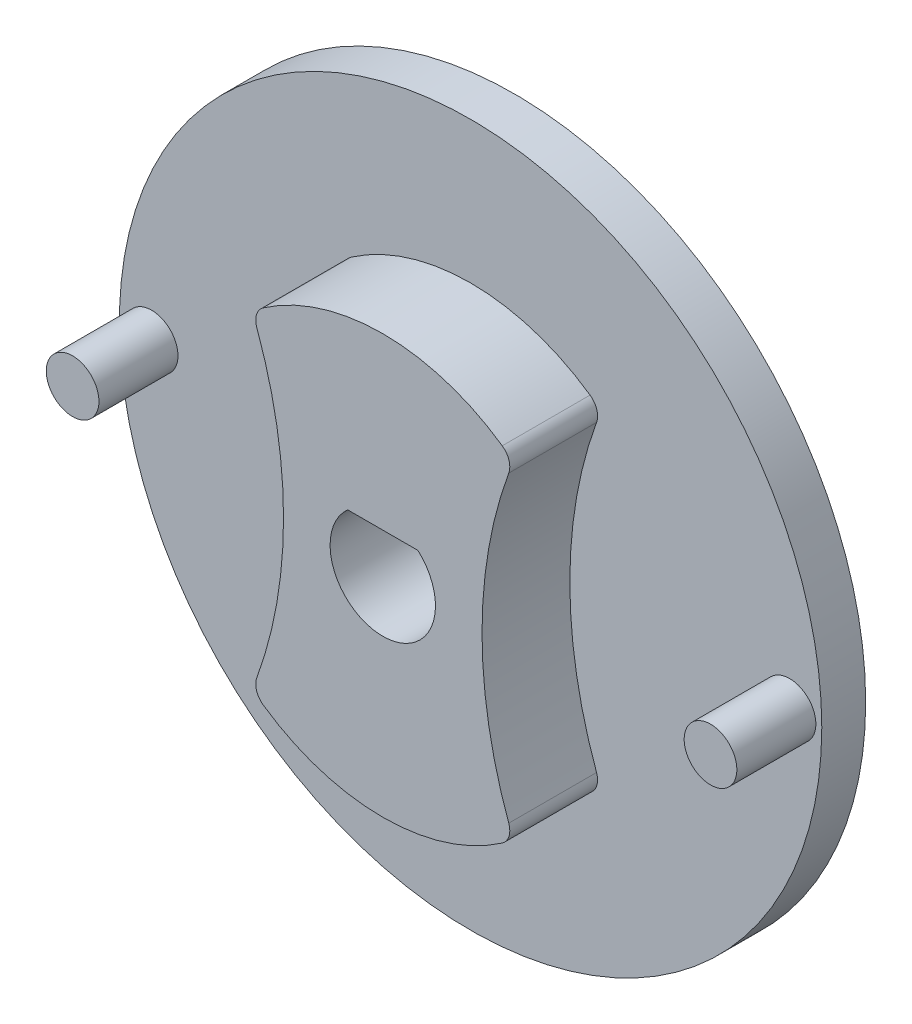
from build123d import *

# Parameters (mm, degrees)
BOSS_EXTRUDE1_DEPTH     = 5
SKETCH2_R               = 20
BOSS_EXTRUDE2_DEPTH     = 2.5
SKETCH3_R               = 1.5
BOSS_EXTRUDE3_DEPTH     = 4.5
CUT_EXTRUDE1_DEPTH      = 46.094423797
CUT_EXTRUDE1_DEPTH_BACK = 46.094423797
FILLET1_R               = 1


with BuildPart() as part:
    # Sketch1 → Boss-Extrude1 (new body)
    with BuildSketch(Plane.XY):
        with BuildLine():
            ThreePointArc((27.055367122, -8.375602421), (25.270767556, 0.948424737), (27.055367122, 10.272451896))
            ThreePointArc((27.055367122, 10.272451896), (19.619068119, 12.874699316), (12.182769116, 10.272451896))
            ThreePointArc((12.182769116, 10.272451896), (13.967368681, 0.948424737), (12.182769116, -8.375602421))
            ThreePointArc((12.182769116, -8.375602421), (19.619068119, -10.977849841), (27.055367122, -8.375602421))
        make_face()
    extrude(amount=BOSS_EXTRUDE1_DEPTH)

    # Sketch2 → Boss-Extrude2 (add)
    with BuildSketch(Plane.XY):
        with Locations((19.619068119, 0.948424737)):
            Circle(SKETCH2_R)
    extrude(amount=-BOSS_EXTRUDE2_DEPTH)

    # Sketch3 → Boss-Extrude3 (add)
    with BuildSketch(Plane.XY):
        with Locations((1.455504919, 0.948424737)):
            Circle(SKETCH3_R)
        with Locations((37.782631319, 0.948424737)):
            Circle(SKETCH3_R)
    extrude(amount=BOSS_EXTRUDE3_DEPTH)

    # Sketch4 → Cut-Extrude1 (cut, two sides: drawn at the far end of the back side and taken through both)
    with BuildSketch(Plane.XY.offset(-CUT_EXTRUDE1_DEPTH_BACK)):
        with BuildLine():
            Line((17.619068119, 3.184492715), (21.619068119, 3.184492715))
            ThreePointArc((21.619068119, 3.184492715), (19.619068119, -2.051575263), (17.619068119, 3.184492715))
        make_face()
    extrude(amount=CUT_EXTRUDE1_DEPTH + CUT_EXTRUDE1_DEPTH_BACK, mode=Mode.SUBTRACT)

    # Fillet1
    fillet1_edges = [part.edges().sort_by_distance(p)[0] for p in [
        (12.182769116, -8.375602421, 2.5),
        (27.055367122, -8.375602421, 2.5),
        (27.055367122, 10.272451896, 2.5),
        (12.182769116, 10.272451896, 2.5),
    ]]
    fillet(fillet1_edges, radius=FILLET1_R)


solid = part.part
